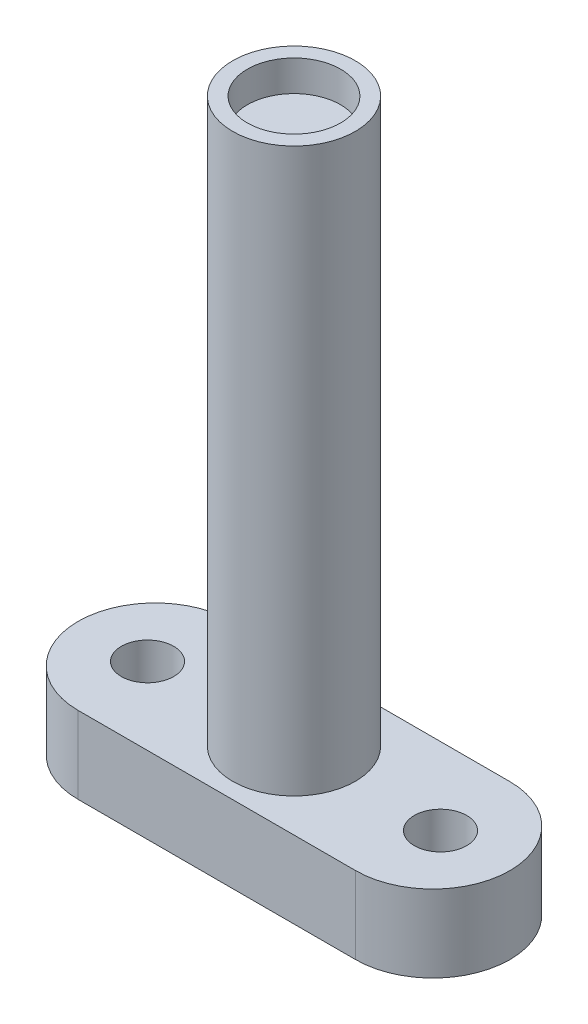
from build123d import *

# Parameters (mm, degrees)
BOSS_EXTRUDE1_DEPTH      = 5
M3_CLEARANCE_HOLE1_D     = 3.4
M3_CLEARANCE_HOLE1_DEPTH = 5
M3_CLEARANCE_HOLE1_TIP   = 1.021463052
SKETCH4_R                = 3.975
BOSS_EXTRUDE2_DEPTH      = 36.5
SKETCH5_R                = 3.025
CUT_EXTRUDE1_DEPTH       = 2


with BuildPart() as part:
    # Sketch1 → Boss-Extrude1 (new body)
    with BuildSketch(Plane(origin=(0, 0, 0), x_dir=(1, 0, 0), z_dir=(0, 1, 0))):
        with BuildLine():
            Line((-9, 5), (9, 5))
            ThreePointArc((9, 5), (14, 0), (9, -5))
            Line((9, -5), (-9, -5))
            ThreePointArc((-9, -5), (-14, 0), (-9, 5))
        make_face()
    extrude(amount=BOSS_EXTRUDE1_DEPTH)

    # M3 Clearance Hole1
    with Locations(Plane(origin=(0, 5, 0), x_dir=(1, 0, 0), z_dir=(0, 1, 0))):
        with Locations((-9.5, 0), (9.5, 0)):
            Hole(M3_CLEARANCE_HOLE1_D / 2, depth=M3_CLEARANCE_HOLE1_DEPTH)
            with Locations((0, 0, -(M3_CLEARANCE_HOLE1_DEPTH + M3_CLEARANCE_HOLE1_TIP / 2))):  # 118° drill point
                Cone(0, M3_CLEARANCE_HOLE1_D / 2, M3_CLEARANCE_HOLE1_TIP, mode=Mode.SUBTRACT)

    # Sketch4 → Boss-Extrude2 (add)
    with BuildSketch(Plane(origin=(0, 5, 0), x_dir=(1, 0, 0), z_dir=(0, 1, 0))):
        Circle(SKETCH4_R)
    extrude(amount=BOSS_EXTRUDE2_DEPTH)

    # Sketch5 → Cut-Extrude1 (cut)
    with BuildSketch(Plane(origin=(0, 41.5, 0), x_dir=(1, 0, 0), z_dir=(0, 1, 0))):
        Circle(SKETCH5_R)
    extrude(amount=-CUT_EXTRUDE1_DEPTH, mode=Mode.SUBTRACT)


solid = part.part
